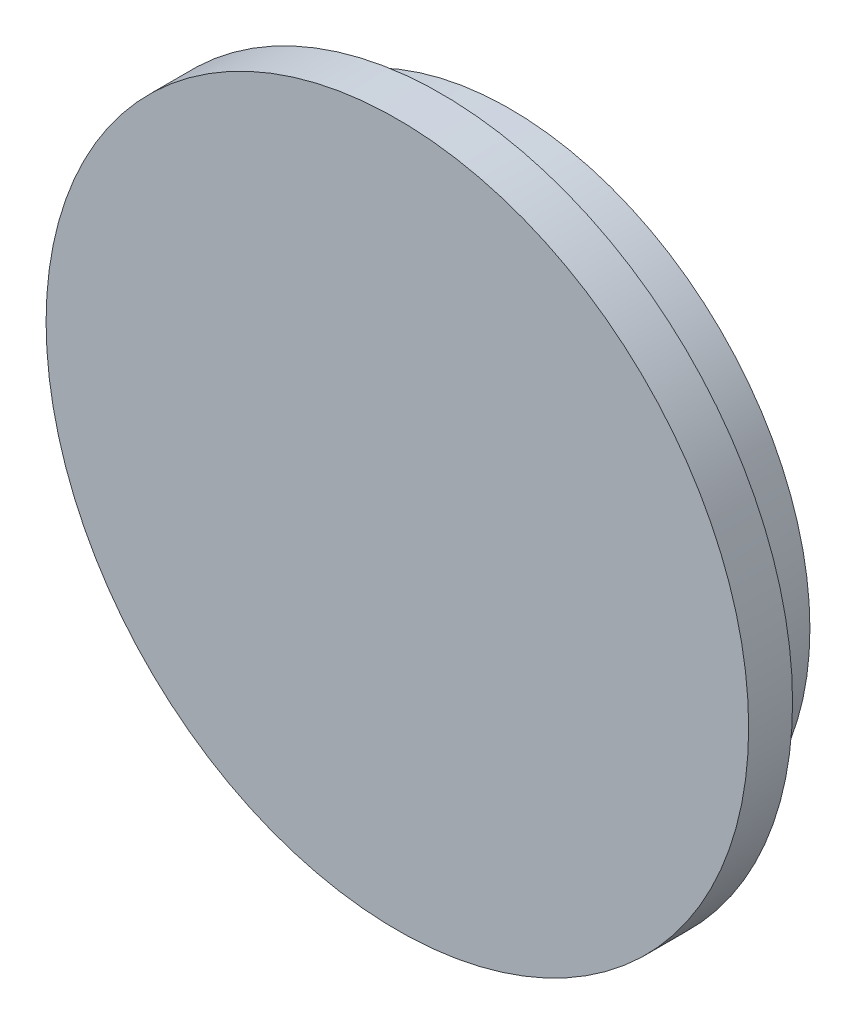
from build123d import *

# Parameters (mm, degrees)
SZKIC1_R                    = 12
DODANIE_WYCI_GNI_CIE1_DEPTH = 1.5
SZKIC1_3_R                  = 10.25
DODANIE_WYCI_GNI_CIE2_DEPTH = 2


with BuildPart() as part:
    # Szkic1 → Dodanie-wyci_gni_cie1 (new body)
    with BuildSketch(Plane.XY):
        Circle(SZKIC1_R)
    extrude(amount=DODANIE_WYCI_GNI_CIE1_DEPTH)

    # Szkic1_3 → Dodanie-wyci_gni_cie2 (add)
    with BuildSketch(Plane.XY):
        with Locations((0.343006843, 0.476494591)):
            Circle(SZKIC1_3_R)
    extrude(amount=-DODANIE_WYCI_GNI_CIE2_DEPTH)


solid = part.part
